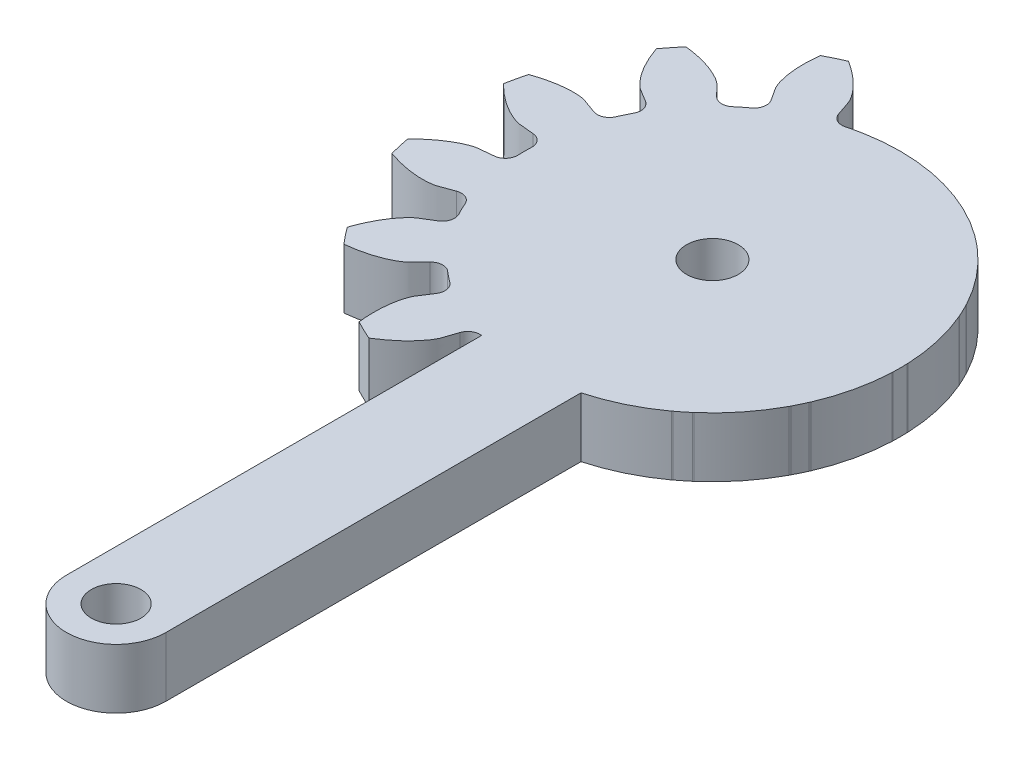
from build123d import *

# Parameters (mm, degrees)
SKETCH1_R           = 1.3
SKETCH1_R_2         = 1
BOSS_EXTRUDE1_DEPTH = 3
CUT_EXTRUDE3_DEPTH  = 10
SKETCH5_R           = 1.25
CUT_EXTRUDE4_DEPTH  = 4.0000001


with BuildPart() as part:
    # Sketch1 → Boss-Extrude1 (new body)
    with BuildSketch(Plane(origin=(0, 2.5, 0), x_dir=(1, 0, 0), z_dir=(0, 1, 0))):
        with BuildLine():
            Line((-9, -29), (-9, -8.113637629))
            ThreePointArc((-9, -8.113637629), (-8.587994536, -8.19683966), (-8.326921567, -8.526251234))
            add(Edge.make_bspline(
                [(-8.326921567, -8.526251234), (-8.206101949, -8.891447218), (-8.082758084, -9.261258663), (-8.064306033, -9.298602555), (-8.032331928, -9.367441209), (-7.988260055, -9.447778411), (-7.924726707, -9.552553062), (-7.841311254, -9.675212686), (-7.735439865, -9.81548422), (-7.605390063, -9.970907224), (-7.449370867, -10.139506596), (-7.265778101, -10.318971305), (-7.053286531, -10.506979774), (-6.810203903, -10.700849594), (-6.552164146, -10.88786672), (-6.366549013, -11.006397327), (-6.279429809, -11.061523152)],
                knots=[0.056243512, 0.056243512, 0.056243512, 0.056243512, 0.172234307, 0.201816834, 0.240007665, 0.285195651, 0.336434003, 0.393080129, 0.454660958, 0.520809377, 0.591229746, 0.665677333, 0.743945196, 0.825855349, 0.911252587, 0.985950699, 0.985950699, 0.985950699, 0.985950699], degree=3))
            ThreePointArc((-6.279429809, -11.061523152), (-5.797528, -10.841305121), (-5.324893747, -10.601842812))
            add(Edge.make_bspline(
                [(-6.030458918, -7.42033311), (-5.820267001, -7.742489662), (-5.608040413, -8.069497444), (-5.590348448, -8.107207374), (-5.556463749, -8.175125935), (-5.521131959, -8.259672139), (-5.478828232, -8.374670436), (-5.434937762, -8.516364288), (-5.391278792, -8.686595744), (-5.350848919, -8.885177432), (-5.316309, -9.11227814), (-5.290466057, -9.367711161), (-5.275961444, -9.651065122), (-5.275947455, -9.96199063), (-5.290616735, -10.280337506), (-5.313674917, -10.499359886), (-5.324893747, -10.601842812)],
                knots=[0.056243512, 0.056243512, 0.056243512, 0.056243512, 0.172234307, 0.201816834, 0.240007665, 0.285195651, 0.336434003, 0.393080129, 0.454660958, 0.520809377, 0.591229746, 0.665677333, 0.743945196, 0.825855349, 0.911252587, 0.985950699, 0.985950699, 0.985950699, 0.985950699], degree=3))
            ThreePointArc((-6.030458918, -7.42033311), (-6.120214516, -6.977795953), (-5.881938155, -6.594234251))
            ThreePointArc((-5.881938155, -6.594234251), (-5.610248122, -6.385515254), (-5.346305425, -6.167081403))
            ThreePointArc((-5.346305425, -6.167081403), (-4.919338938, -6.020129636), (-4.507869611, -6.206108655))
            add(Edge.make_bspline(
                [(-4.507869611, -6.206108655), (-4.240562298, -6.4827172), (-3.968978143, -6.762388901), (-3.936150512, -6.78802854), (-3.877474866, -6.83617698), (-3.802910475, -6.889436229), (-3.700208889, -6.956268842), (-3.571834147, -7.030588735), (-3.415585783, -7.111033146), (-3.230979446, -7.194637939), (-3.017258482, -7.278846533), (-2.773980296, -7.360880733), (-2.50095819, -7.438073873), (-2.197831347, -7.507274946), (-1.88420187, -7.5638123), (-1.66553991, -7.590069299), (-1.56313002, -7.601936345)],
                knots=[0.056243512, 0.056243512, 0.056243512, 0.056243512, 0.172234307, 0.201816834, 0.240007665, 0.285195651, 0.336434003, 0.393080129, 0.454660958, 0.520809377, 0.591229746, 0.665677333, 0.743945196, 0.825855349, 0.911252587, 0.985950699, 0.985950699, 0.985950699, 0.985950699], degree=3))
            ThreePointArc((-1.56313002, -7.601936345), (-1.224500516, -7.194437396), (-0.90257057, -6.773620994))
            add(Edge.make_bspline(
                [(-2.91866815, -4.213313054), (-2.589513286, -4.412367223), (-2.256420378, -4.614909388), (-2.224118743, -4.641208605), (-2.164120925, -4.687699094), (-2.095604859, -4.748542703), (-2.007594627, -4.83379769), (-1.906572021, -4.942416077), (-1.793375988, -5.076846403), (-1.670788566, -5.238220457), (-1.54113387, -5.427844815), (-1.407021949, -5.646769182), (-1.271011068, -5.895768964), (-1.136092942, -6.175897097), (-1.011183974, -6.469082484), (-0.936928429, -6.6764194), (-0.90257057, -6.773620994)],
                knots=[0.056243512, 0.056243512, 0.056243512, 0.056243512, 0.172234307, 0.201816834, 0.240007665, 0.285195651, 0.336434003, 0.393080129, 0.454660958, 0.520809377, 0.591229746, 0.665677333, 0.743945196, 0.825855349, 0.911252587, 0.985950699, 0.985950699, 0.985950699, 0.985950699], degree=3))
            ThreePointArc((-2.91866815, -4.213313054), (-3.191544825, -3.853544346), (-3.143286427, -3.404582956))
            ThreePointArc((-3.143286427, -3.404582956), (-2.989061944, -3.09865175), (-2.846032688, -2.787329206))
            ThreePointArc((-2.846032688, -2.787329206), (-2.525109158, -2.469676424), (-2.073694832, -2.458707879))
            add(Edge.make_bspline(
                [(-2.073694832, -2.458707879), (-1.712843315, -2.59194327), (-1.346809442, -2.726082817), (-1.306108147, -2.734939959), (-1.232352391, -2.752861796), (-1.142063874, -2.768494444), (-1.020535359, -2.784147999), (-0.872627519, -2.795408196), (-0.696949086, -2.800092482), (-0.494349763, -2.79532011), (-0.265257089, -2.77845938), (-0.010477711, -2.746815192), (0.268999555, -2.697903956), (0.572132623, -2.62873016), (0.879233657, -2.543589825), (1.08763376, -2.472372695), (1.185050801, -2.438630548)],
                knots=[0.056243512, 0.056243512, 0.056243512, 0.056243512, 0.172234307, 0.201816834, 0.240007665, 0.285195651, 0.336434003, 0.393080129, 0.454660958, 0.520809377, 0.591229746, 0.665677333, 0.743945196, 0.825855349, 0.911252587, 0.985950699, 0.985950699, 0.985950699, 0.985950699], degree=3))
            ThreePointArc((1.185050801, -2.438630548), (1.313338274, -1.924560846), (1.420801739, -1.4057382))
            add(Edge.make_bspline(
                [(-1.506515397, 0.02626759), (-1.123590744, -0.010259076), (-0.735604653, -0.048219666), (-0.695091083, -0.057899287), (-0.620863449, -0.073753693), (-0.532733555, -0.098843883), (-0.416448323, -0.137469763), (-0.278302348, -0.191499483), (-0.117989113, -0.263503103), (0.062475915, -0.355707413), (0.261565686, -0.470297992), (0.477384074, -0.60935305), (0.7079626, -0.774681192), (0.951062673, -0.968529138), (1.190810137, -1.178484073), (1.347672187, -1.333069907), (1.420801739, -1.4057382)],
                knots=[0.056243512, 0.056243512, 0.056243512, 0.056243512, 0.172234307, 0.201816834, 0.240007665, 0.285195651, 0.336434003, 0.393080129, 0.454660958, 0.520809377, 0.591229746, 0.665677333, 0.743945196, 0.825855349, 0.911252587, 0.985950699, 0.985950699, 0.985950699, 0.985950699], degree=3))
            ThreePointArc((-1.506515397, 0.02626759), (-1.908466578, 0.232011243), (-2.059784311, 0.657450012))
            ThreePointArc((-2.059784311, 0.657450012), (-2.053571429, 1), (-2.059784311, 1.342549988))
            ThreePointArc((-2.059784311, 1.342549988), (-1.908466578, 1.767988757), (-1.506515397, 1.97373241))
            add(Edge.make_bspline(
                [(-1.506515397, 1.97373241), (-1.123590744, 2.010259076), (-0.735604653, 2.048219666), (-0.695091083, 2.057899287), (-0.620863449, 2.073753693), (-0.532733555, 2.098843883), (-0.416448323, 2.137469763), (-0.278302348, 2.191499483), (-0.117989113, 2.263503103), (0.062475915, 2.355707413), (0.261565686, 2.470297992), (0.477384074, 2.60935305), (0.7079626, 2.774681192), (0.951062673, 2.968529138), (1.190810137, 3.178484073), (1.347672187, 3.333069907), (1.420801739, 3.4057382)],
                knots=[0.056243512, 0.056243512, 0.056243512, 0.056243512, 0.172234307, 0.201816834, 0.240007665, 0.285195651, 0.336434003, 0.393080129, 0.454660958, 0.520809377, 0.591229746, 0.665677333, 0.743945196, 0.825855349, 0.911252587, 0.985950699, 0.985950699, 0.985950699, 0.985950699], degree=3))
            ThreePointArc((1.420801739, 3.4057382), (1.313338274, 3.924560846), (1.185050801, 4.438630548))
            add(Edge.make_bspline(
                [(-2.073694832, 4.458707879), (-1.712843315, 4.59194327), (-1.346809442, 4.726082817), (-1.306108147, 4.734939959), (-1.232352391, 4.752861796), (-1.142063874, 4.768494444), (-1.020535359, 4.784147999), (-0.872627519, 4.795408196), (-0.696949086, 4.800092482), (-0.494349763, 4.79532011), (-0.265257089, 4.77845938), (-0.010477712, 4.746815192), (0.268999555, 4.697903956), (0.572132623, 4.62873016), (0.879233657, 4.543589825), (1.08763376, 4.472372695), (1.185050801, 4.438630548)],
                knots=[0.056243512, 0.056243512, 0.056243512, 0.056243512, 0.172234307, 0.201816834, 0.240007665, 0.285195651, 0.336434003, 0.393080129, 0.454660958, 0.520809377, 0.591229746, 0.665677333, 0.743945196, 0.825855349, 0.911252587, 0.985950699, 0.985950699, 0.985950699, 0.985950699], degree=3))
            ThreePointArc((-2.073694832, 4.458707879), (-2.525109158, 4.469676424), (-2.846032688, 4.787329206))
            ThreePointArc((-2.846032688, 4.787329206), (-2.989061944, 5.09865175), (-3.143286427, 5.404582956))
            ThreePointArc((-3.143286427, 5.404582956), (-3.191544825, 5.853544346), (-2.91866815, 6.213313054))
            add(Edge.make_bspline(
                [(-2.91866815, 6.213313054), (-2.589513286, 6.412367223), (-2.256420378, 6.614909388), (-2.224118743, 6.641208605), (-2.164120925, 6.687699094), (-2.095604859, 6.748542703), (-2.007594627, 6.83379769), (-1.906572021, 6.942416077), (-1.793375988, 7.076846403), (-1.670788566, 7.238220457), (-1.54113387, 7.427844815), (-1.407021949, 7.646769182), (-1.271011068, 7.895768964), (-1.136092942, 8.175897097), (-1.011183974, 8.469082484), (-0.936928429, 8.6764194), (-0.90257057, 8.773620994)],
                knots=[0.056243512, 0.056243512, 0.056243512, 0.056243512, 0.172234307, 0.201816834, 0.240007665, 0.285195651, 0.336434003, 0.393080129, 0.454660958, 0.520809377, 0.591229746, 0.665677333, 0.743945196, 0.825855349, 0.911252587, 0.985950699, 0.985950699, 0.985950699, 0.985950699], degree=3))
            ThreePointArc((-0.90257057, 8.773620994), (-1.224500516, 9.194437396), (-1.56313002, 9.601936345))
            add(Edge.make_bspline(
                [(-4.507869611, 8.206108655), (-4.240562298, 8.4827172), (-3.968978143, 8.762388901), (-3.936150512, 8.78802854), (-3.877474866, 8.83617698), (-3.802910475, 8.889436229), (-3.700208889, 8.956268842), (-3.571834147, 9.030588735), (-3.415585783, 9.111033146), (-3.230979446, 9.194637939), (-3.017258482, 9.278846533), (-2.773980296, 9.360880733), (-2.50095819, 9.438073873), (-2.197831347, 9.507274946), (-1.88420187, 9.5638123), (-1.66553991, 9.590069299), (-1.56313002, 9.601936345)],
                knots=[0.056243512, 0.056243512, 0.056243512, 0.056243512, 0.172234307, 0.201816834, 0.240007665, 0.285195651, 0.336434003, 0.393080129, 0.454660958, 0.520809377, 0.591229746, 0.665677333, 0.743945196, 0.825855349, 0.911252587, 0.985950699, 0.985950699, 0.985950699, 0.985950699], degree=3))
            ThreePointArc((-4.507869611, 8.206108655), (-4.919338938, 8.020129636), (-5.346305425, 8.167081403))
            ThreePointArc((-5.346305425, 8.167081403), (-5.610248122, 8.385515254), (-5.881938155, 8.594234251))
            ThreePointArc((-5.881938155, 8.594234251), (-6.120214516, 8.977795953), (-6.030458918, 9.42033311))
            add(Edge.make_bspline(
                [(-6.030458918, 9.42033311), (-5.820267001, 9.742489662), (-5.608040413, 10.069497444), (-5.590348448, 10.107207374), (-5.556463749, 10.175125935), (-5.521131959, 10.259672139), (-5.478828232, 10.374670436), (-5.434937762, 10.516364288), (-5.391278792, 10.686595744), (-5.350848919, 10.885177432), (-5.316309, 11.11227814), (-5.290466057, 11.367711161), (-5.275961444, 11.651065122), (-5.275947455, 11.96199063), (-5.290616735, 12.280337506), (-5.313674917, 12.499359886), (-5.324893747, 12.601842812)],
                knots=[0.056243512, 0.056243512, 0.056243512, 0.056243512, 0.172234307, 0.201816834, 0.240007665, 0.285195651, 0.336434003, 0.393080129, 0.454660958, 0.520809377, 0.591229746, 0.665677333, 0.743945196, 0.825855349, 0.911252587, 0.985950699, 0.985950699, 0.985950699, 0.985950699], degree=3))
            ThreePointArc((-5.324893747, 12.601842812), (-5.797528, 12.841305121), (-6.279429809, 13.061523152))
            add(Edge.make_bspline(
                [(-8.326921567, 10.526251234), (-8.206101949, 10.891447218), (-8.082758084, 11.261258663), (-8.064306033, 11.298602555), (-8.032331928, 11.367441209), (-7.988260055, 11.447778411), (-7.924726707, 11.552553062), (-7.841311254, 11.675212686), (-7.735439865, 11.81548422), (-7.605390063, 11.970907224), (-7.449370867, 12.139506596), (-7.265778101, 12.318971305), (-7.053286531, 12.506979774), (-6.810203903, 12.700849594), (-6.552164146, 12.88786672), (-6.366549013, 13.006397327), (-6.279429809, 13.061523152)],
                knots=[0.056243512, 0.056243512, 0.056243512, 0.056243512, 0.172234307, 0.201816834, 0.240007665, 0.285195651, 0.336434003, 0.393080129, 0.454660958, 0.520809377, 0.591229746, 0.665677333, 0.743945196, 0.825855349, 0.911252587, 0.985950699, 0.985950699, 0.985950699, 0.985950699], degree=3))
            ThreePointArc((-8.326921567, 10.526251234), (-8.616949349, 10.180160078), (-9.065392843, 10.127305229))
            ThreePointArc((-9.065392843, 10.127305229), (-9.397971892, 10.209586885), (-9.733315933, 10.279754316))
            ThreePointArc((-9.733315933, 10.279754316), (-10.114416701, 10.521947229), (-10.225559378, 10.959602925))
            add(Edge.make_bspline(
                [(-10.225559378, 10.959602925), (-10.175961493, 11.341054805), (-10.126635304, 11.727760301), (-10.12705712, 11.769412029), (-10.12599682, 11.845306558), (-10.1308472, 11.936809945), (-10.142628751, 12.058774731), (-10.164563462, 12.205479841), (-10.199088749, 12.377796001), (-10.248824058, 12.574253783), (-10.316239971, 12.793850761), (-10.403784518, 13.035200793), (-10.51365899, 13.296787206), (-10.648551907, 13.576927478), (-10.799894005, 13.857383341), (-10.915698959, 14.044711117), (-10.97027245, 14.132177375)],
                knots=[0.056243512, 0.056243512, 0.056243512, 0.056243512, 0.172234307, 0.201816834, 0.240007665, 0.285195651, 0.336434003, 0.393080129, 0.454660958, 0.520809377, 0.591229746, 0.665677333, 0.743945196, 0.825855349, 0.911252587, 0.985950699, 0.985950699, 0.985950699, 0.985950699], degree=3))
            ThreePointArc((-10.97027245, 14.132177375), (-11.5, 14.142857143), (-12.02972755, 14.132177375))
            add(Edge.make_bspline(
                [(-12.774440622, 10.959602925), (-12.824038507, 11.341054805), (-12.873364696, 11.727760301), (-12.87294288, 11.769412029), (-12.87400318, 11.845306558), (-12.8691528, 11.936809945), (-12.857371249, 12.058774731), (-12.835436538, 12.205479841), (-12.800911251, 12.377796001), (-12.751175942, 12.574253783), (-12.683760029, 12.793850761), (-12.596215482, 13.035200793), (-12.48634101, 13.296787206), (-12.351448093, 13.576927478), (-12.200105995, 13.857383341), (-12.084301041, 14.044711117), (-12.02972755, 14.132177375)],
                knots=[0.056243512, 0.056243512, 0.056243512, 0.056243512, 0.172234307, 0.201816834, 0.240007665, 0.285195651, 0.336434003, 0.393080129, 0.454660958, 0.520809377, 0.591229746, 0.665677333, 0.743945196, 0.825855349, 0.911252587, 0.985950699, 0.985950699, 0.985950699, 0.985950699], degree=3))
            ThreePointArc((-12.774440622, 10.959602925), (-12.885583299, 10.521947229), (-13.266684067, 10.279754316))
            ThreePointArc((-13.266684067, 10.279754316), (-13.602028108, 10.209586885), (-13.934607157, 10.127305229))
            ThreePointArc((-13.934607157, 10.127305229), (-14.383050651, 10.180160078), (-14.673078433, 10.526251234))
            add(Edge.make_bspline(
                [(-14.673078433, 10.526251234), (-14.793898051, 10.891447218), (-14.917241916, 11.261258663), (-14.935693967, 11.298602555), (-14.967668072, 11.367441209), (-15.011739945, 11.447778411), (-15.075273293, 11.552553062), (-15.158688746, 11.675212686), (-15.264560135, 11.81548422), (-15.394609937, 11.970907224), (-15.550629133, 12.139506596), (-15.734221899, 12.318971305), (-15.946713469, 12.506979774), (-16.189796097, 12.700849594), (-16.447835854, 12.88786672), (-16.633450987, 13.006397327), (-16.720570191, 13.061523152)],
                knots=[0.056243512, 0.056243512, 0.056243512, 0.056243512, 0.172234307, 0.201816834, 0.240007665, 0.285195651, 0.336434003, 0.393080129, 0.454660958, 0.520809377, 0.591229746, 0.665677333, 0.743945196, 0.825855349, 0.911252587, 0.985950699, 0.985950699, 0.985950699, 0.985950699], degree=3))
            ThreePointArc((-16.720570191, 13.061523152), (-17.202472, 12.841305121), (-17.675106253, 12.601842812))
            add(Edge.make_bspline(
                [(-16.969541082, 9.42033311), (-17.179732999, 9.742489662), (-17.391959587, 10.069497444), (-17.409651552, 10.107207374), (-17.443536251, 10.175125935), (-17.478868041, 10.259672139), (-17.521171768, 10.374670436), (-17.565062238, 10.516364288), (-17.608721208, 10.686595744), (-17.649151081, 10.885177432), (-17.683691, 11.11227814), (-17.709533943, 11.367711161), (-17.724038556, 11.651065122), (-17.724052545, 11.96199063), (-17.709383265, 12.280337506), (-17.686325083, 12.499359886), (-17.675106253, 12.601842812)],
                knots=[0.056243512, 0.056243512, 0.056243512, 0.056243512, 0.172234307, 0.201816834, 0.240007665, 0.285195651, 0.336434003, 0.393080129, 0.454660958, 0.520809377, 0.591229746, 0.665677333, 0.743945196, 0.825855349, 0.911252587, 0.985950699, 0.985950699, 0.985950699, 0.985950699], degree=3))
            ThreePointArc((-16.969541082, 9.42033311), (-16.879785484, 8.977795953), (-17.118061845, 8.594234251))
            ThreePointArc((-17.118061845, 8.594234251), (-17.389751878, 8.385515254), (-17.653694575, 8.167081403))
            ThreePointArc((-17.653694575, 8.167081403), (-18.080661062, 8.020129636), (-18.492130389, 8.206108655))
            add(Edge.make_bspline(
                [(-18.492130389, 8.206108655), (-18.759437702, 8.4827172), (-19.031021857, 8.762388901), (-19.063849488, 8.78802854), (-19.122525134, 8.83617698), (-19.197089525, 8.889436229), (-19.299791111, 8.956268842), (-19.428165853, 9.030588735), (-19.584414217, 9.111033146), (-19.769020554, 9.194637939), (-19.982741518, 9.278846533), (-20.226019704, 9.360880733), (-20.49904181, 9.438073873), (-20.802168653, 9.507274946), (-21.11579813, 9.5638123), (-21.33446009, 9.590069299), (-21.43686998, 9.601936345)],
                knots=[0.056243512, 0.056243512, 0.056243512, 0.056243512, 0.172234307, 0.201816834, 0.240007665, 0.285195651, 0.336434003, 0.393080129, 0.454660958, 0.520809377, 0.591229746, 0.665677333, 0.743945196, 0.825855349, 0.911252587, 0.985950699, 0.985950699, 0.985950699, 0.985950699], degree=3))
            ThreePointArc((-21.43686998, 9.601936345), (-21.775499484, 9.194437396), (-22.09742943, 8.773620994))
            add(Edge.make_bspline(
                [(-20.08133185, 6.213313054), (-20.410486714, 6.412367223), (-20.743579622, 6.614909388), (-20.775881257, 6.641208605), (-20.835879075, 6.687699094), (-20.904395141, 6.748542703), (-20.992405373, 6.83379769), (-21.093427979, 6.942416077), (-21.206624012, 7.076846403), (-21.329211434, 7.238220457), (-21.45886613, 7.427844815), (-21.592978051, 7.646769182), (-21.728988932, 7.895768964), (-21.863907058, 8.175897097), (-21.988816026, 8.469082484), (-22.063071571, 8.6764194), (-22.09742943, 8.773620994)],
                knots=[0.056243512, 0.056243512, 0.056243512, 0.056243512, 0.172234307, 0.201816834, 0.240007665, 0.285195651, 0.336434003, 0.393080129, 0.454660958, 0.520809377, 0.591229746, 0.665677333, 0.743945196, 0.825855349, 0.911252587, 0.985950699, 0.985950699, 0.985950699, 0.985950699], degree=3))
            ThreePointArc((-20.08133185, 6.213313054), (-19.808455175, 5.853544346), (-19.856713573, 5.404582956))
            ThreePointArc((-19.856713573, 5.404582956), (-20.010938056, 5.09865175), (-20.153967312, 4.787329206))
            ThreePointArc((-20.153967312, 4.787329206), (-20.474890842, 4.469676424), (-20.926305168, 4.458707879))
            add(Edge.make_bspline(
                [(-20.926305168, 4.458707879), (-21.287156685, 4.59194327), (-21.653190558, 4.726082817), (-21.693891853, 4.734939959), (-21.767647609, 4.752861796), (-21.857936126, 4.768494444), (-21.979464641, 4.784147999), (-22.127372481, 4.795408196), (-22.303050914, 4.800092482), (-22.505650237, 4.79532011), (-22.734742911, 4.77845938), (-22.989522289, 4.746815192), (-23.268999555, 4.697903956), (-23.572132623, 4.62873016), (-23.879233657, 4.543589825), (-24.08763376, 4.472372695), (-24.185050801, 4.438630548)],
                knots=[0.056243512, 0.056243512, 0.056243512, 0.056243512, 0.172234307, 0.201816834, 0.240007665, 0.285195651, 0.336434003, 0.393080129, 0.454660958, 0.520809377, 0.591229746, 0.665677333, 0.743945196, 0.825855349, 0.911252587, 0.985950699, 0.985950699, 0.985950699, 0.985950699], degree=3))
            ThreePointArc((-24.185050801, 4.438630548), (-24.313338274, 3.924560846), (-24.420801739, 3.4057382))
            add(Edge.make_bspline(
                [(-21.493484603, 1.97373241), (-21.876409256, 2.010259076), (-22.264395347, 2.048219666), (-22.304908917, 2.057899287), (-22.379136551, 2.073753693), (-22.467266445, 2.098843883), (-22.583551677, 2.137469763), (-22.721697652, 2.191499483), (-22.882010887, 2.263503103), (-23.062475915, 2.355707413), (-23.261565686, 2.470297992), (-23.477384074, 2.60935305), (-23.7079626, 2.774681192), (-23.951062673, 2.968529138), (-24.190810137, 3.178484073), (-24.347672187, 3.333069907), (-24.420801739, 3.4057382)],
                knots=[0.056243512, 0.056243512, 0.056243512, 0.056243512, 0.172234307, 0.201816834, 0.240007665, 0.285195651, 0.336434003, 0.393080129, 0.454660958, 0.520809377, 0.591229746, 0.665677333, 0.743945196, 0.825855349, 0.911252587, 0.985950699, 0.985950699, 0.985950699, 0.985950699], degree=3))
            ThreePointArc((-21.493484603, 1.97373241), (-21.091533422, 1.767988757), (-20.940215689, 1.342549988))
            ThreePointArc((-20.940215689, 1.342549988), (-20.946428571, 1), (-20.940215689, 0.657450012))
            ThreePointArc((-20.940215689, 0.657450012), (-21.091533422, 0.232011243), (-21.493484603, 0.02626759))
            add(Edge.make_bspline(
                [(-21.493484603, 0.02626759), (-21.876409256, -0.010259076), (-22.264395347, -0.048219666), (-22.304908917, -0.057899287), (-22.379136551, -0.073753693), (-22.467266445, -0.098843883), (-22.583551677, -0.137469763), (-22.721697652, -0.191499483), (-22.882010887, -0.263503103), (-23.062475915, -0.355707413), (-23.261565686, -0.470297992), (-23.477384074, -0.60935305), (-23.7079626, -0.774681192), (-23.951062673, -0.968529138), (-24.190810137, -1.178484073), (-24.347672187, -1.333069907), (-24.420801739, -1.4057382)],
                knots=[0.056243512, 0.056243512, 0.056243512, 0.056243512, 0.172234307, 0.201816834, 0.240007665, 0.285195651, 0.336434003, 0.393080129, 0.454660958, 0.520809377, 0.591229746, 0.665677333, 0.743945196, 0.825855349, 0.911252587, 0.985950699, 0.985950699, 0.985950699, 0.985950699], degree=3))
            ThreePointArc((-24.420801739, -1.4057382), (-24.313338274, -1.924560846), (-24.185050801, -2.438630548))
            add(Edge.make_bspline(
                [(-20.926305168, -2.458707879), (-21.287156685, -2.59194327), (-21.653190558, -2.726082817), (-21.693891853, -2.734939959), (-21.767647609, -2.752861796), (-21.857936126, -2.768494444), (-21.979464641, -2.784147999), (-22.127372481, -2.795408196), (-22.303050914, -2.800092482), (-22.505650237, -2.79532011), (-22.734742911, -2.77845938), (-22.989522288, -2.746815192), (-23.268999555, -2.697903956), (-23.572132623, -2.62873016), (-23.879233657, -2.543589825), (-24.08763376, -2.472372695), (-24.185050801, -2.438630548)],
                knots=[0.056243512, 0.056243512, 0.056243512, 0.056243512, 0.172234307, 0.201816834, 0.240007665, 0.285195651, 0.336434003, 0.393080129, 0.454660958, 0.520809377, 0.591229746, 0.665677333, 0.743945196, 0.825855349, 0.911252587, 0.985950699, 0.985950699, 0.985950699, 0.985950699], degree=3))
            ThreePointArc((-20.926305168, -2.458707879), (-20.474890842, -2.469676424), (-20.153967312, -2.787329206))
            ThreePointArc((-20.153967312, -2.787329206), (-20.010938056, -3.09865175), (-19.856713573, -3.404582956))
            ThreePointArc((-19.856713573, -3.404582956), (-19.808455175, -3.853544346), (-20.08133185, -4.213313054))
            add(Edge.make_bspline(
                [(-20.08133185, -4.213313054), (-20.410486714, -4.412367223), (-20.743579622, -4.614909388), (-20.775881257, -4.641208605), (-20.835879075, -4.687699094), (-20.904395141, -4.748542703), (-20.992405373, -4.83379769), (-21.093427979, -4.942416077), (-21.206624012, -5.076846403), (-21.329211434, -5.238220457), (-21.45886613, -5.427844815), (-21.592978051, -5.646769182), (-21.728988932, -5.895768964), (-21.863907058, -6.175897097), (-21.988816026, -6.469082484), (-22.063071571, -6.6764194), (-22.09742943, -6.773620994)],
                knots=[0.056243512, 0.056243512, 0.056243512, 0.056243512, 0.172234307, 0.201816834, 0.240007665, 0.285195651, 0.336434003, 0.393080129, 0.454660958, 0.520809377, 0.591229746, 0.665677333, 0.743945196, 0.825855349, 0.911252587, 0.985950699, 0.985950699, 0.985950699, 0.985950699], degree=3))
            ThreePointArc((-22.09742943, -6.773620994), (-21.775499484, -7.194437396), (-21.43686998, -7.601936345))
            add(Edge.make_bspline(
                [(-18.492130389, -6.206108655), (-18.759437702, -6.4827172), (-19.031021857, -6.762388901), (-19.063849488, -6.78802854), (-19.122525134, -6.83617698), (-19.197089525, -6.889436229), (-19.299791111, -6.956268842), (-19.428165853, -7.030588735), (-19.584414217, -7.111033146), (-19.769020554, -7.194637939), (-19.982741518, -7.278846533), (-20.226019704, -7.360880733), (-20.49904181, -7.438073873), (-20.802168653, -7.507274946), (-21.11579813, -7.5638123), (-21.33446009, -7.590069299), (-21.43686998, -7.601936345)],
                knots=[0.056243512, 0.056243512, 0.056243512, 0.056243512, 0.172234307, 0.201816834, 0.240007665, 0.285195651, 0.336434003, 0.393080129, 0.454660958, 0.520809377, 0.591229746, 0.665677333, 0.743945196, 0.825855349, 0.911252587, 0.985950699, 0.985950699, 0.985950699, 0.985950699], degree=3))
            ThreePointArc((-18.492130389, -6.206108655), (-18.080661062, -6.020129636), (-17.653694575, -6.167081403))
            ThreePointArc((-17.653694575, -6.167081403), (-17.389751878, -6.385515254), (-17.118061845, -6.594234251))
            ThreePointArc((-17.118061845, -6.594234251), (-16.879785484, -6.977795953), (-16.969541082, -7.42033311))
            add(Edge.make_bspline(
                [(-16.969541082, -7.42033311), (-17.179732999, -7.742489662), (-17.391959587, -8.069497444), (-17.409651552, -8.107207374), (-17.443536251, -8.175125935), (-17.478868041, -8.259672139), (-17.521171768, -8.374670436), (-17.565062238, -8.516364288), (-17.608721208, -8.686595744), (-17.649151081, -8.885177432), (-17.683691, -9.11227814), (-17.709533943, -9.367711161), (-17.724038556, -9.651065122), (-17.724052545, -9.96199063), (-17.709383265, -10.280337506), (-17.686325083, -10.499359886), (-17.675106253, -10.601842812)],
                knots=[0.056243512, 0.056243512, 0.056243512, 0.056243512, 0.172234307, 0.201816834, 0.240007665, 0.285195651, 0.336434003, 0.393080129, 0.454660958, 0.520809377, 0.591229746, 0.665677333, 0.743945196, 0.825855349, 0.911252587, 0.985950699, 0.985950699, 0.985950699, 0.985950699], degree=3))
            ThreePointArc((-17.675106253, -10.601842812), (-17.202472, -10.841305121), (-16.720570191, -11.061523152))
            add(Edge.make_bspline(
                [(-14.673078433, -8.526251234), (-14.793898051, -8.891447218), (-14.917241916, -9.261258663), (-14.935693967, -9.298602555), (-14.967668072, -9.367441209), (-15.011739945, -9.447778411), (-15.075273292, -9.552553062), (-15.158688746, -9.675212686), (-15.264560135, -9.81548422), (-15.394609937, -9.970907224), (-15.550629133, -10.139506596), (-15.734221899, -10.318971305), (-15.946713469, -10.506979774), (-16.189796097, -10.700849594), (-16.447835854, -10.88786672), (-16.633450987, -11.006397327), (-16.720570191, -11.061523152)],
                knots=[0.056243512, 0.056243512, 0.056243512, 0.056243512, 0.172234307, 0.201816834, 0.240007665, 0.285195651, 0.336434003, 0.393080129, 0.454660958, 0.520809377, 0.591229746, 0.665677333, 0.743945196, 0.825855349, 0.911252587, 0.985950699, 0.985950699, 0.985950699, 0.985950699], degree=3))
            ThreePointArc((-14.673078433, -8.526251234), (-14.412005464, -8.19683966), (-14, -8.113637629))
            Line((-14, -8.113637629), (-14, -29))
            ThreePointArc((-14, -29), (-11.5, -31.5), (-9, -29))
        make_face()
        with Locations((-11.5, 1)):
            Circle(SKETCH1_R, mode=Mode.SUBTRACT)
        with Locations((-11.5, -29)):
            Circle(SKETCH1_R_2, mode=Mode.SUBTRACT)
    extrude(amount=-BOSS_EXTRUDE1_DEPTH)

    # Sketch4 → Cut-Extrude3 (cut)
    with BuildSketch(Plane.XZ.offset(0.5)):
        with BuildLine():
            Line((-9, 12.567496439), (-9, 8.113637629))
            ThreePointArc((-9, 8.113637629), (-2.37745059, -3.467282534), (-13.934533302, -10.131343737))
            Line((-13.934533302, -10.131343737), (-13.841754887, -15.204621321))
            Line((-13.841754887, -15.204621321), (-4.777587301, -15.204621321))
            Line((-4.777587301, -15.204621321), (2.506902603, -7.060156914))
            Line((2.506902603, -7.060156914), (2.506902603, 7.761756572))
            Line((2.506902603, 7.761756572), (-9, 12.567496439))
        make_face()
    extrude(amount=-CUT_EXTRUDE3_DEPTH, mode=Mode.SUBTRACT)

    # Sketch5 → Cut-Extrude4 (cut, through all)
    with BuildSketch(Plane.XZ.offset(0.5)):
        with Locations((-11.5, 29)):
            Circle(SKETCH5_R)
    extrude(amount=-CUT_EXTRUDE4_DEPTH, mode=Mode.SUBTRACT)


solid = part.part
